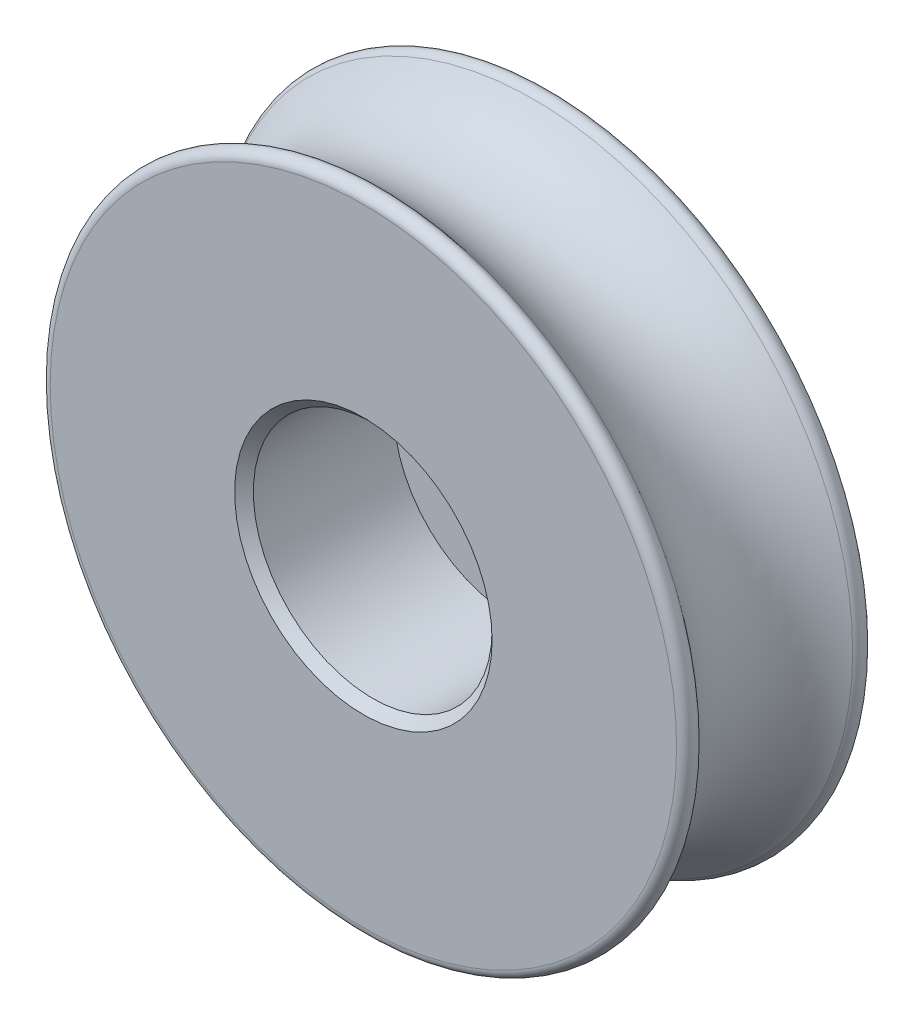
from build123d import *

# Parameters (mm, degrees)
FILLET1_R     = 0.2
CHAMFER2_SIZE = 0.2


with BuildPart() as part:
    # Sketch2 → Revolve1 (revolve)
    with BuildSketch(Plane(origin=(0, 0, 0), x_dir=(1, 0, 0), z_dir=(0, 1, 0))):
        with BuildLine():
            Line((1.1, 4), (7.55, 4))
            ThreePointArc((7.55, 4), (6, 2), (7.55, 0))
            Line((7.55, 0), (2.55, 0))
            Line((2.55, 0), (2.55, 3.2))
            Line((2.55, 3.2), (1.1, 3.2))
            Line((1.1, 3.2), (1.1, 4))
        make_face()
    revolve(axis=Axis((0, 0, 0), (0, 0, -1)))

    # Fillet1
    fillet1_edges = [part.edges().sort_by_distance(p)[0] for p in [
        (-7.55, 0, -4),
        (-7.55, 0, 0),
    ]]
    fillet(fillet1_edges, radius=FILLET1_R)

    # Chamfer2
    chamfer2_edges = [part.edges().sort_by_distance(p)[0] for p in [
        (-1.1, 0, -4),
        (-2.55, 0, 0),
    ]]
    chamfer(chamfer2_edges, length=CHAMFER2_SIZE)


solid = part.part
